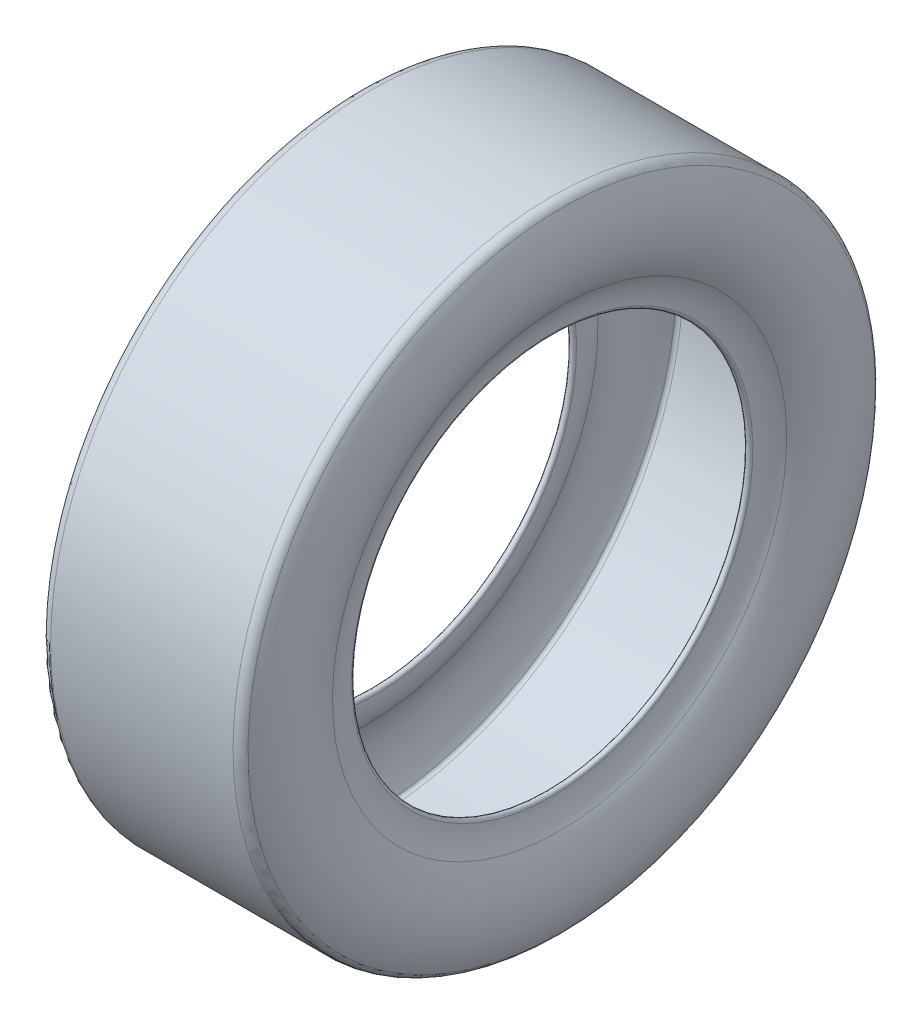
from build123d import *


with BuildPart() as part:
    # Sketch3 → Tire (revolve)
    with BuildSketch(Plane.XY):
        with BuildLine():
            Line((-76.2, 266.7), (76.2, 266.7))
            ThreePointArc((76.2, 266.7), (80.767657764, 265.436260402), (84.036197426, 262.004470242))
            ThreePointArc((84.036197426, 262.004470242), (92.688846001, 225.632798379), (82.300183103, 189.718420692))
            ThreePointArc((82.300183103, 189.718420692), (77.753090494, 179.092826007), (76.2, 167.64))
            ThreePointArc((76.2, 167.64), (73.66, 165.1), (71.12, 167.64))
            ThreePointArc((71.12, 167.64), (72.856553296, 180.445720486), (77.940782895, 192.326490828))
            ThreePointArc((77.940782895, 192.326490828), (87.610310346, 225.754763968), (79.556624926, 259.608675965))
            ThreePointArc((79.556624926, 259.608675965), (78.156550234, 261.078678795), (76.2, 261.62))
            Line((76.2, 261.62), (-76.2, 261.62))
            ThreePointArc((-76.2, 261.62), (-78.156550234, 261.078678795), (-79.556624926, 259.608675965))
            ThreePointArc((-79.556624926, 259.608675965), (-87.610310346, 225.754763968), (-77.940782895, 192.326490828))
            ThreePointArc((-77.940782895, 192.326490828), (-72.856553296, 180.445720486), (-71.12, 167.64))
            ThreePointArc((-71.12, 167.64), (-73.66, 165.1), (-76.2, 167.64))
            ThreePointArc((-76.2, 167.64), (-77.753090494, 179.092826007), (-82.300183103, 189.718420692))
            ThreePointArc((-82.300183103, 189.718420692), (-92.688846001, 225.632798379), (-84.036197426, 262.004470242))
            ThreePointArc((-84.036197426, 262.004470242), (-80.767657764, 265.436260402), (-76.2, 266.7))
        make_face()
    revolve(axis=Axis((-23.17871602, 0, 0), (1, 0, 0)))


solid = part.part
